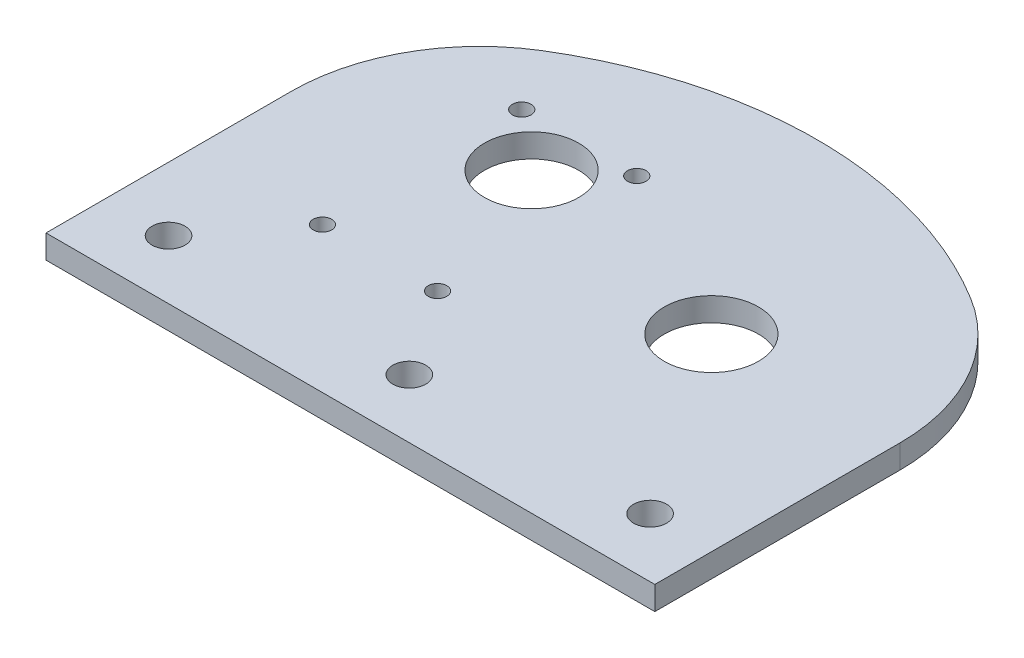
from build123d import *

# Parameters (mm, degrees)
SKETCH3_R                = 6.35
SKETCH3_R_2              = 1.25
BOSS_EXTRUDE4_DEPTH      = 1.5875
BOSS_EXTRUDE7_DEPTH      = 1.5875
BOSS_EXTRUDE7_DEPTH_BACK = 1.5875
SKETCH9_R                = 6.35
CUT_EXTRUDE3_DEPTH       = 4.175
SKETCH11_W               = 82.024989992
SKETCH11_H               = 3.175
BOSS_EXTRUDE8_DEPTH      = 7.62
SKETCH10_R               = 2.2225
CUT_EXTRUDE4_DEPTH       = 4.175


with BuildPart() as part:
    # Sketch3 → Boss-Extrude4 (new body, symmetric)
    with BuildSketch(Plane(origin=(0, 0, 0), x_dir=(1, 0, 0), z_dir=(0, 1, 0))):
        with BuildLine():
            Line((-25.4, 0), (-25.4, -25.4))
            Line((-25.4, -25.4), (0, -25.4))
            Line((0, -25.4), (25.4, -25.4))
            Line((25.4, -25.4), (25.4, 0))
            ThreePointArc((25.4, 0), (0, 25.4), (-25.4, 0))
        make_face()
        with Locations((0, 7)):
            Circle(SKETCH3_R, mode=Mode.SUBTRACT)
        with Locations((7.75, 13.423393759)):
            Circle(SKETCH3_R_2, mode=Mode.SUBTRACT)
        with Locations((-7.75, 13.423393759)):
            Circle(SKETCH3_R_2, mode=Mode.SUBTRACT)
        with Locations((-7.75, -13.423393759)):
            Circle(SKETCH3_R_2, mode=Mode.SUBTRACT)
        with Locations((7.75, -13.423393759)):
            Circle(SKETCH3_R_2, mode=Mode.SUBTRACT)
    extrude(amount=BOSS_EXTRUDE4_DEPTH, both=True)

    # Sketch8 → Boss-Extrude7 (add, two sides)
    with BuildSketch(Plane(origin=(0, 0, 0), x_dir=(1, 0, 0), z_dir=(0, 1, 0))) as boss_extrude7_sk:
        with BuildLine():
            Line((25.4, -25.4), (25.4, 0))
            ThreePointArc((25.4, 0), (12.395970521, 22.169797357), (-13.300780696, 21.639067283))
            ThreePointArc((-13.300780696, 21.639067283), (15.612494996, 29.814593742), (44.525770688, 21.639067283))
            ThreePointArc((44.525770688, 21.639067283), (53.394787349, 12.395970521), (56.624989992, 0))
            Line((56.624989992, 0), (56.624989992, -25.4))
            Line((56.624989992, -25.4), (25.4, -25.4))
        make_face()
    extrude(amount=BOSS_EXTRUDE7_DEPTH)
    extrude(boss_extrude7_sk.sketch, amount=-BOSS_EXTRUDE7_DEPTH_BACK)

    # Sketch9 → Cut-Extrude3 (cut, through all)
    with BuildSketch(Plane(origin=(0, 1.5875, 0), x_dir=(1, 0, 0), z_dir=(0, 1, 0))):
        with Locations((31.224989992, 0)):
            Circle(SKETCH9_R)
    extrude(amount=-CUT_EXTRUDE3_DEPTH, mode=Mode.SUBTRACT)

    # Sketch11 → Boss-Extrude8 (add)
    with BuildSketch(Plane.XY.offset(25.4)):
        with Locations((15.612494996, 0)):
            Rectangle(SKETCH11_W, SKETCH11_H)
    extrude(amount=BOSS_EXTRUDE8_DEPTH)

    # Sketch10 → Cut-Extrude4 (cut, through all)
    with BuildSketch(Plane(origin=(0, -1.5875, 0), x_dir=(-1, 0, 0), z_dir=(0, -1, 0))):
        with Locations((-15.612494996, -25.0825)):
            Circle(SKETCH10_R)
        with Locations((-48.052489992, -25.0825)):
            Circle(SKETCH10_R)
        with Locations((16.8275, -25.0825)):
            Circle(SKETCH10_R)
    extrude(amount=-CUT_EXTRUDE4_DEPTH, mode=Mode.SUBTRACT)


solid = part.part
